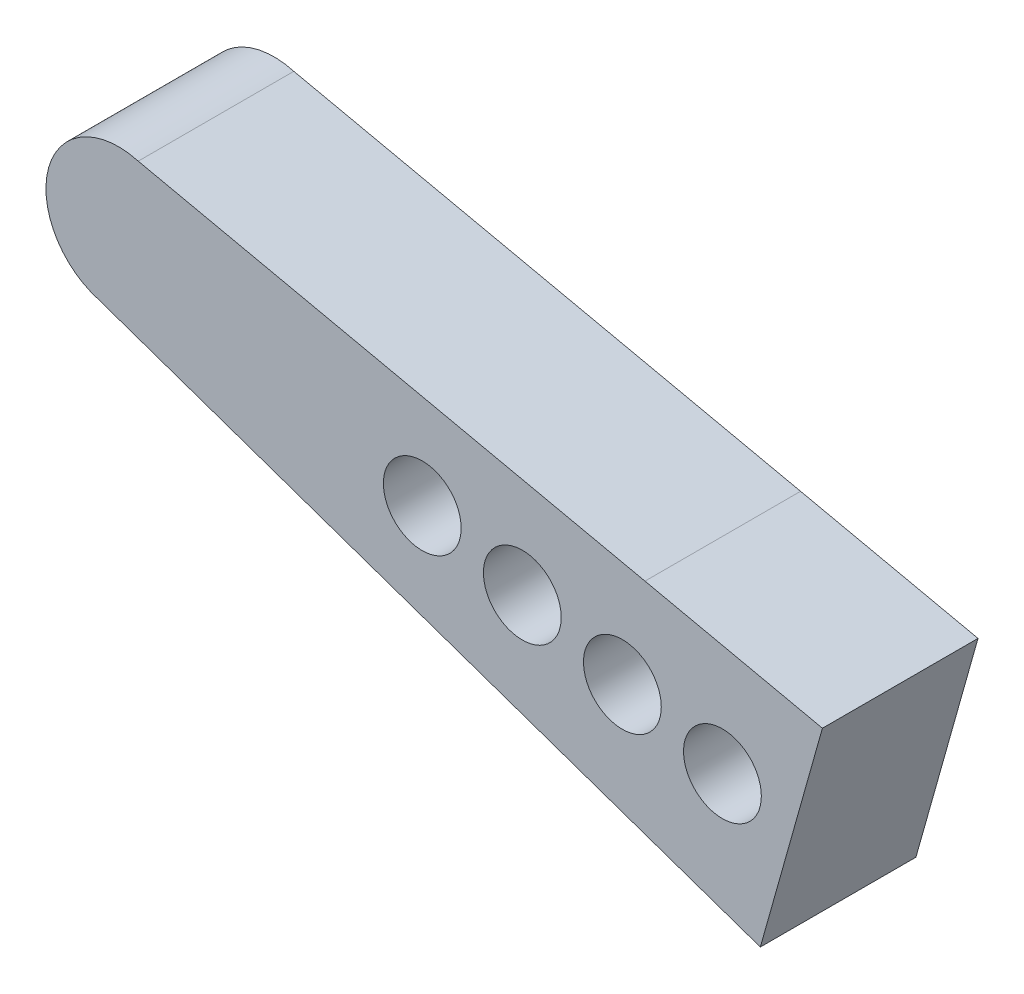
from build123d import *

# Parameters (mm, degrees)
SKETCH1_R           = 0.75
BOSS_EXTRUDE1_DEPTH = 3


with BuildPart() as part:
    # Sketch1 → Boss-Extrude1 (new body)
    with BuildSketch(Plane.XY):
        with BuildLine():
            Line((-0.759056855, 15.743363502), (-10.20503728, 19.025657487))
            ThreePointArc((-10.20503728, 19.025657487), (-11.173300847, 20.75263915), (-9.446319184, 21.720902717))
            Line((-9.446319184, 21.720902717), (0.32477793, 19.593542575))
            Line((0.32477793, 19.593542575), (3.74605929, 18.847766175))
            Line((3.74605929, 18.847766175), (2.548854641, 14.594855726))
            Line((2.548854641, 14.594855726), (-0.759056855, 15.743363502))
        make_face()
        with Locations((-3.96973296, 18.704410315)):
            Circle(SKETCH1_R, mode=Mode.SUBTRACT)
        with Locations((-2.040406529, 18.177438286)):
            Circle(SKETCH1_R, mode=Mode.SUBTRACT)
        with Locations((-0.111080097, 17.650466256)):
            Circle(SKETCH1_R, mode=Mode.SUBTRACT)
        with Locations((1.818246335, 17.123494227)):
            Circle(SKETCH1_R, mode=Mode.SUBTRACT)
    extrude(amount=BOSS_EXTRUDE1_DEPTH)


solid = part.part
